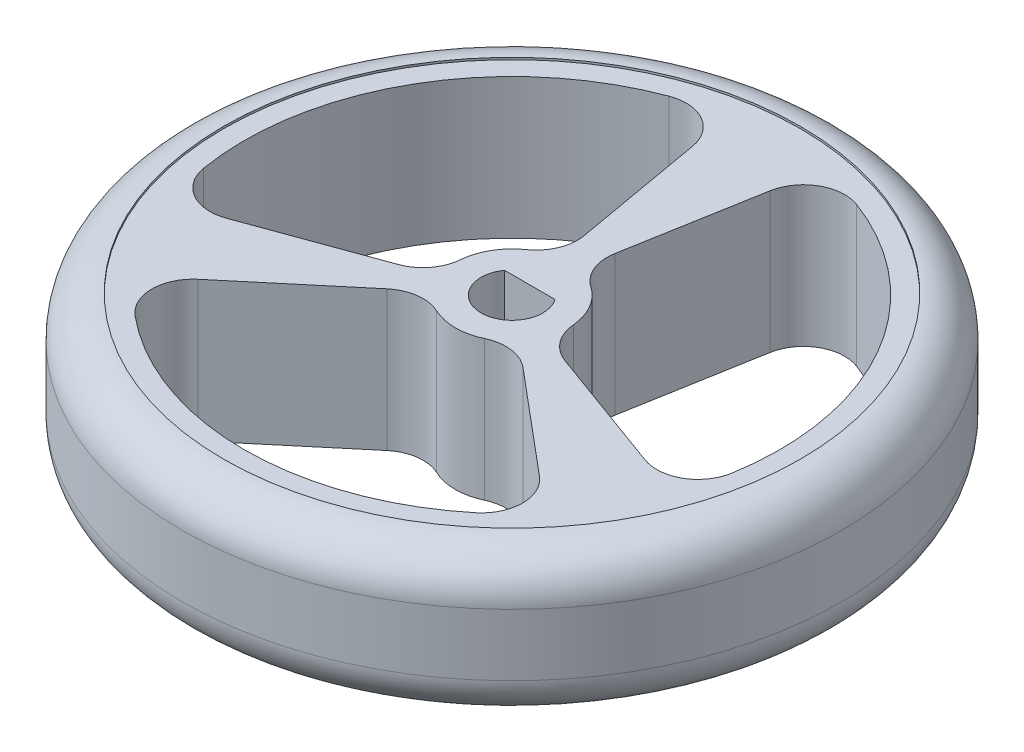
from build123d import *

# Parameters (mm, degrees)
SKETCH1_R           = 16
SKETCH1_R_2         = 13
SKETCH1_R_3         = 2.75
BOSS_EXTRUDE1_DEPTH = 3.5
FILLET2_R           = 2
FILLET3_R           = 2
SKETCH4_R           = 14
CUT_EXTRUDE2_DEPTH  = 0.1


with BuildPart() as part:
    # Sketch1 → Boss-Extrude1 (new body, symmetric)
    with BuildSketch(Plane(origin=(0, 0, 0), x_dir=(1, 0, 0), z_dir=(0, 1, 0))):
        Circle(SKETCH1_R)
        Circle(SKETCH1_R_2, mode=Mode.SUBTRACT)
        with BuildLine():
            ThreePointArc((-2.106622219, -1.767665927), (-2.38156986, -1.375), (-2.584154707, -0.940555394))
            Line((-2.584154707, -0.940555394), (-12.21600407, -4.446261863))
            ThreePointArc((-12.21600407, -4.446261863), (-11.258330249, -6.5), (-9.958577761, -8.356238926))
            Line((-9.958577761, -8.356238926), (-2.106622219, -1.767665927))
        make_face()
        Circle(SKETCH1_R_3)
        with BuildLine():
            ThreePointArc((-1.227230113, 0.8625), (0, -1.5), (1.227230113, 0.8625))
            Line((1.227230113, 0.8625), (-1.227230113, 0.8625))
        make_face(mode=Mode.SUBTRACT)
        with BuildLine():
            Line((-2.25742631, 12.802500789), (-0.477532489, 2.708221321))
            ThreePointArc((-0.477532489, 2.708221321), (0, 2.75), (0.477532489, 2.708221321))
            Line((0.477532489, 2.708221321), (2.25742631, 12.802500789))
            ThreePointArc((2.25742631, 12.802500789), (0, 13), (-2.25742631, 12.802500789))
        make_face()
        with BuildLine():
            Line((12.21600407, -4.446261863), (2.584154707, -0.940555394))
            ThreePointArc((2.584154707, -0.940555394), (2.38156986, -1.375), (2.106622219, -1.767665927))
            Line((2.106622219, -1.767665927), (9.958577761, -8.356238926))
            ThreePointArc((9.958577761, -8.356238926), (11.258330249, -6.5), (12.21600407, -4.446261863))
        make_face()
    extrude(amount=BOSS_EXTRUDE1_DEPTH, both=True)

    # Fillet2
    fillet2_edges = [part.edges().sort_by_distance(p)[0] for p in [
        (-16, -3.5, 0),
        (-16, 3.5, 0),
    ]]
    fillet(fillet2_edges, radius=FILLET2_R)

    # Fillet3
    fillet3_edges = [part.edges().sort_by_distance(p)[0] for p in [
        (2.584154707, 0, 0.940555394),
        (12.21600407, 0, 4.446261863),
        (2.25742631, 0, -12.802500789),
        (0.477532489, 0, -2.708221321),
        (-2.25742631, 0, -12.802500789),
        (-12.21600407, 0, 4.446261863),
        (-2.584154707, 0, 0.940555394),
        (-0.477532489, 0, -2.708221321),
        (-9.958577761, 0, 8.356238926),
        (9.958577761, 0, 8.356238926),
        (2.106622219, 0, 1.767665927),
        (-2.106622219, 0, 1.767665927),
    ]]
    fillet(fillet3_edges, radius=FILLET3_R)

    # Sketch4 → Cut-Extrude2 (cut)
    with BuildSketch(Plane(origin=(0, 3.5, 0), x_dir=(1, 0, 0), z_dir=(0, 1, 0))):
        Circle(SKETCH4_R)
    cut_extrude2 = extrude(amount=-CUT_EXTRUDE2_DEPTH, mode=Mode.SUBTRACT)

    # Mirror1: Cut-Extrude2 across plane
    add(cut_extrude2.mirror(Plane.ZX), mode=Mode.SUBTRACT)


solid = part.part
